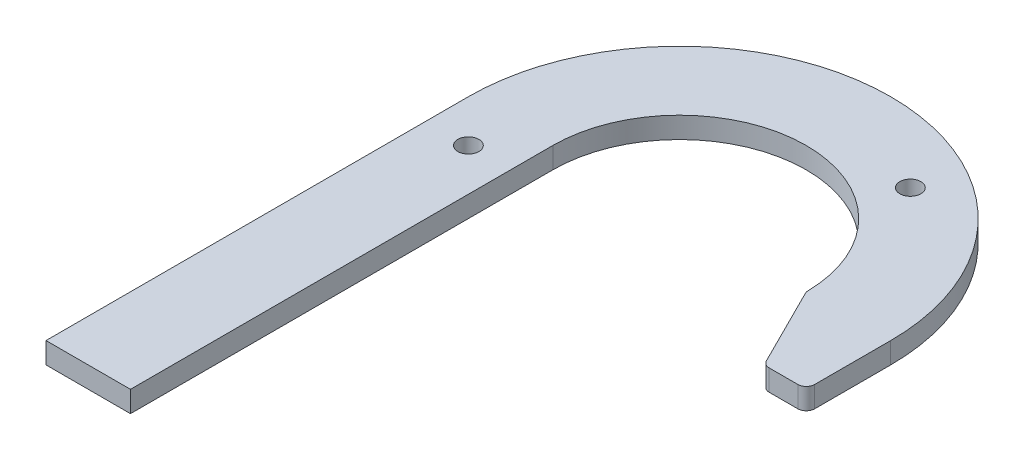
from build123d import *

# Parameters (mm, degrees)
SKETCH1_R           = 3.175
BOSS_EXTRUDE1_DEPTH = 6.35


with BuildPart() as part:
    # Sketch1 → Boss-Extrude1 (new body)
    with BuildSketch(Plane(origin=(0, 6.35, 0), x_dir=(1, 0, 0), z_dir=(0, 1, 0))):
        with BuildLine():
            Line((90.469806331, 44.117768919), (99.06, 44.117768919))
            ThreePointArc((99.06, 44.117768919), (100.856051224, 44.861717695), (101.6, 46.657768919))
            Line((101.6, 46.657768919), (101.6, 69.517768919))
            ThreePointArc((101.6, 69.517768919), (38.1, 133.017768919), (-25.4, 69.517768919))
            Line((-25.4, 69.517768919), (-25.4, -57.482231081))
            Line((-25.4, -57.482231081), (0, -57.482231081))
            Line((0, -57.482231081), (0, 69.517768919))
            ThreePointArc((0, 69.517768919), (37.814649281, 107.616700334), (76.19572572, 70.088454351))
            ThreePointArc((76.19572572, 70.088454351), (76.267828346, 69.524429509), (76.463595703, 68.990577514))
            Line((76.463595703, 68.990577514), (88.197961266, 45.521846387))
            ThreePointArc((88.197961266, 45.521846387), (89.134449307, 44.497115866), (90.469806331, 44.117768919))
        make_face()
        with Locations((64.743779314, 112.270663754)):
            Circle(SKETCH1_R, mode=Mode.SUBTRACT)
        with Locations((-12.7, 56.817768919)):
            Circle(SKETCH1_R, mode=Mode.SUBTRACT)
    extrude(amount=-BOSS_EXTRUDE1_DEPTH)


solid = part.part
